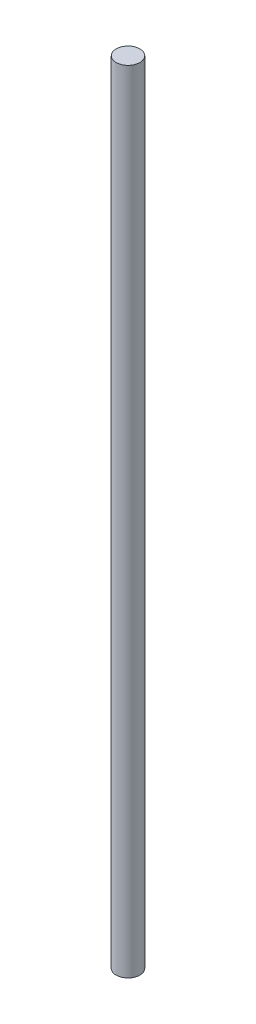
from build123d import *

# Parameters (mm, degrees)
SKETCH_2_R      = 1.5
EXTRUDE_1_DEPTH = 100


with BuildPart() as part:
    # Эскиз2 → Бобышка-Вытянуть1 (new body)
    with BuildSketch(Plane(origin=(0, 0, 0), x_dir=(1, 0, 0), z_dir=(0, 1, 0))):
        Circle(SKETCH_2_R)
    extrude(amount=EXTRUDE_1_DEPTH)


solid = part.part
